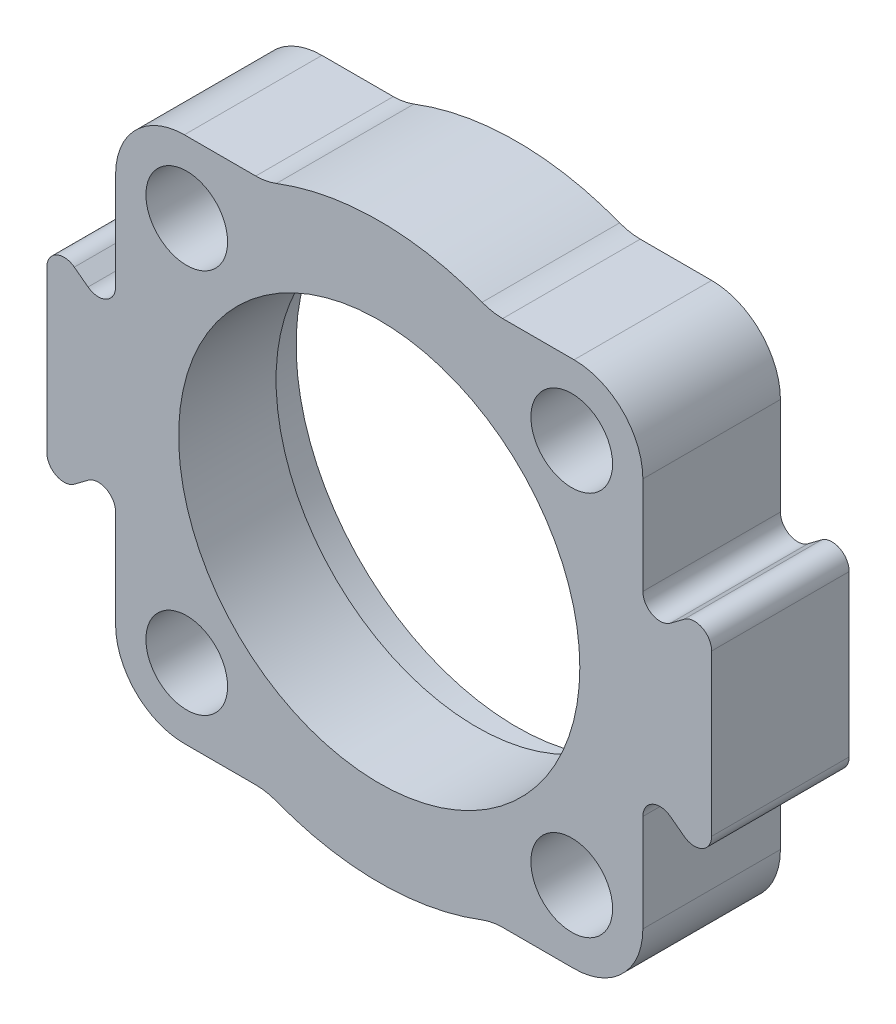
from build123d import *

# Parameters (mm, degrees)
SKETCH1_R                  = 31
BASE_EXTRUDE_DEPTH         = 12.5
SKETCH4_R                  = 7.125
F_4_STK_14_25_HULLER_DEPTH = 25


with BuildPart() as part:
    # Sketch1 → Base-Extrude (new body, symmetric)
    with BuildSketch(Plane.XY):
        with BuildLine():
            Line((34, 46), (21.540659229, 46))
            ThreePointArc((21.540659229, 46), (19.71491737, 46.168079197), (17.950549357, 46.666666667))
            ThreePointArc((17.950549357, 46.666666667), (0, 50), (-17.950549357, 46.666666667))
            ThreePointArc((-17.950549357, 46.666666667), (-19.71491737, 46.168079197), (-21.540659229, 46))
            Line((-21.540659229, 46), (-34, 46))
            ThreePointArc((-34, 46), (-42.485281374, 42.485281374), (-46, 34))
            Line((-46, 34), (-46, 17))
            ThreePointArc((-46, 17), (-47.658359214, 14.316718427), (-50.8, 14.6))
            Line((-50.8, 14.6), (-53.2, 16.4))
            ThreePointArc((-53.2, 16.4), (-56.341640786, 16.683281573), (-58, 14))
            Line((-58, 14), (-58, -14))
            ThreePointArc((-58, -14), (-56.341640786, -16.683281573), (-53.2, -16.4))
            Line((-53.2, -16.4), (-50.8, -14.6))
            ThreePointArc((-50.8, -14.6), (-47.658359214, -14.316718427), (-46, -17))
            Line((-46, -17), (-46, -34))
            ThreePointArc((-46, -34), (-42.485281374, -42.485281374), (-34, -46))
            Line((-34, -46), (-21.540659229, -46))
            ThreePointArc((-21.540659229, -46), (-19.71491737, -46.168079197), (-17.950549357, -46.666666667))
            ThreePointArc((-17.950549357, -46.666666667), (0, -50), (17.950549357, -46.666666667))
            ThreePointArc((17.950549357, -46.666666667), (19.71491737, -46.168079197), (21.540659229, -46))
            Line((21.540659229, -46), (34, -46))
            ThreePointArc((34, -46), (42.485281374, -42.485281374), (46, -34))
            Line((46, -34), (46, -17))
            ThreePointArc((46, -17), (47.658359214, -14.316718427), (50.8, -14.6))
            Line((50.8, -14.6), (53.2, -16.4))
            ThreePointArc((53.2, -16.4), (56.341640786, -16.683281573), (58, -14))
            Line((58, -14), (58, 14))
            ThreePointArc((58, 14), (56.341640786, 16.683281573), (53.2, 16.4))
            Line((53.2, 16.4), (50.8, 14.6))
            ThreePointArc((50.8, 14.6), (47.658359214, 14.316718427), (46, 17))
            Line((46, 17), (46, 34))
            ThreePointArc((46, 34), (42.485281374, 42.485281374), (34, 46))
        make_face()
        Circle(SKETCH1_R, mode=Mode.SUBTRACT)
    extrude(amount=BASE_EXTRUDE_DEPTH, both=True)

    # Sketch2 → Uddrejning (revolve, cut)
    with BuildSketch(Plane(origin=(0, 0, 0), x_dir=(0, 0, -1), z_dir=(1, 0, 0))):
        Polygon((11.5, 38.5), (4.5, 38.5), (4.5, 35), (-12.5, 35), (-12.5, 0), (12.5, 0), (12.5, 70), (11.5, 70), align=None)
    revolve(axis=Axis((0, 0, 0), (0, 0, -1)), mode=Mode.SUBTRACT)

    # Sketch4 → 4 stk ø14.25 huller (cut, through all)
    with BuildSketch(Plane.XY.offset(-11.5)):
        with Locations((33.587572106, 33.587572106)):
            Circle(SKETCH4_R)
        with Locations((33.587572106, -33.587572106)):
            Circle(SKETCH4_R)
        with Locations((-33.587572106, -33.587572106)):
            Circle(SKETCH4_R)
        with Locations((-33.587572106, 33.587572106)):
            Circle(SKETCH4_R)
    extrude(amount=F_4_STK_14_25_HULLER_DEPTH, mode=Mode.SUBTRACT)


solid = part.part
